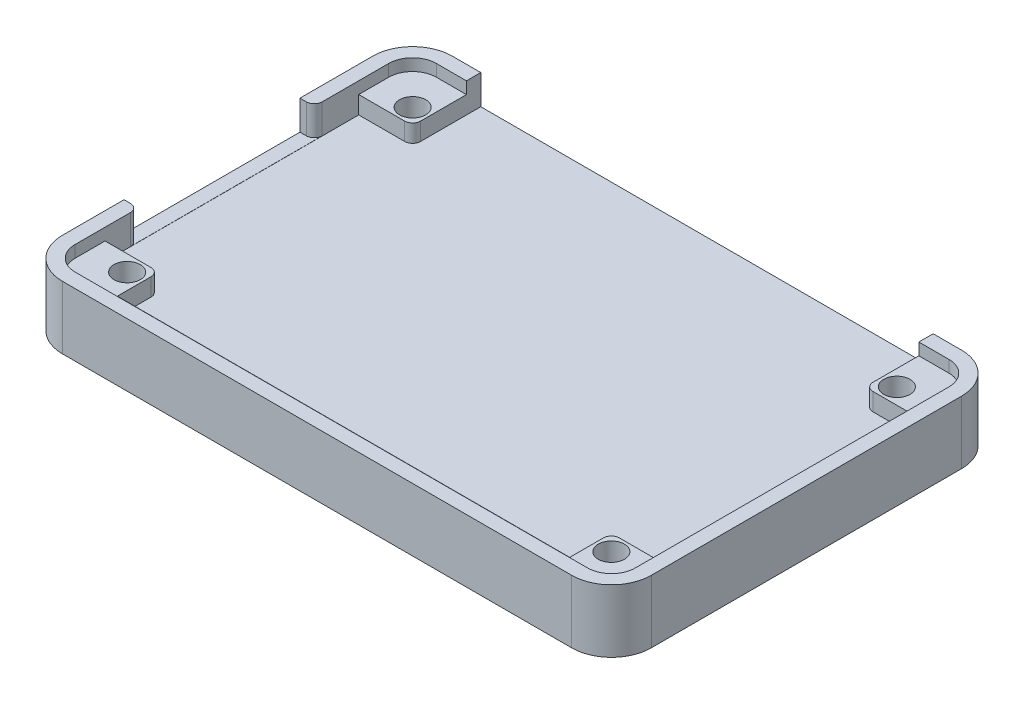
from build123d import *

# Parameters (mm, degrees)
SKETCH1_W           = 74
SKETCH1_H           = 49
BOSS_EXTRUDE1_DEPTH = 7.9
FILLET1_R           = 5
CUT_EXTRUDE4_DEPTH  = 3.72
SKETCH3_R           = 1.65
CUT_EXTRUDE6_DEPTH  = 7.9
SKETCH7_W           = 22.1
SKETCH7_H           = 3.7
CUT_EXTRUDE7_DEPTH  = 3
SKETCH8_W           = 70.4
SKETCH8_H           = 45.4
CUT_EXTRUDE8_DEPTH  = 1.5
FILLET3_R           = 3
FILLET4_R           = 1
FILLET5_R           = 1
FILLET6_R           = 1


with BuildPart() as part:
    # Sketch1 → Boss-Extrude1 (new body)
    with BuildSketch(Plane(origin=(0, 0, 0), x_dir=(1, 0, 0), z_dir=(0, 1, 0))):
        Rectangle(SKETCH1_W, SKETCH1_H)
    extrude(amount=BOSS_EXTRUDE1_DEPTH)

    # Fillet1
    fillet1_edges = [part.edges().sort_by_distance(p)[0] for p in [
        (37, 3.95, 24.5),
        (-37, 3.95, 24.5),
        (-37, 3.95, -24.5),
        (37, 3.95, -24.5),
    ]]
    fillet(fillet1_edges, radius=FILLET1_R)

    # Sketch5 → Cut-Extrude4 (cut)
    with BuildSketch(Plane(origin=(0, 7.9, 0), x_dir=(1, 0, 0), z_dir=(0, 1, 0))):
        Polygon((-35.2, 15.9375), (-28.424, 15.9375), (-28.424, 21.171805633), (-28.424, 24.5), (28.424, 24.5), (28.424, 21.171805633), (28.424, 15.9375), (35.2, 15.9375), (35.2, -15.9375), (28.424, -15.9375), (28.424, -21.17), (-28.424, -21.17), (-28.424, -15.9375), (-35.2, -15.9375), align=None)
    extrude(amount=-CUT_EXTRUDE4_DEPTH, mode=Mode.SUBTRACT)

    # Sketch3 → Cut-Extrude6 (cut)
    with BuildSketch(Plane(origin=(0, 7.9, 0), x_dir=(1, 0, 0), z_dir=(0, 1, 0))):
        with Locations((-30.424, 17.9375)):
            Circle(SKETCH3_R)
        with Locations((30.424, 17.9375)):
            Circle(SKETCH3_R)
        with Locations((-30.424, -17.9375)):
            Circle(SKETCH3_R)
        with Locations((30.424, -17.9375)):
            Circle(SKETCH3_R)
    extrude(amount=-CUT_EXTRUDE6_DEPTH, mode=Mode.SUBTRACT)

    # Sketch7 → Cut-Extrude7 (cut)
    with BuildSketch(Plane.ZY.offset(37)):
        with Locations((0.7, 6.05)):
            Rectangle(SKETCH7_W, SKETCH7_H)
    extrude(amount=-CUT_EXTRUDE7_DEPTH, mode=Mode.SUBTRACT)

    # Sketch8 → Cut-Extrude8 (cut)
    with BuildSketch(Plane(origin=(0, 7.9, 0), x_dir=(1, 0, 0), z_dir=(0, 1, 0))):
        Rectangle(SKETCH8_W, SKETCH8_H)
    extrude(amount=-CUT_EXTRUDE8_DEPTH, mode=Mode.SUBTRACT)

    # Fillet3
    fillet3_edges = [part.edges().sort_by_distance(p)[0] for p in [
        (-35.2, 7.15, -22.7),
        (35.2, 7.15, -22.7),
        (-35.2, 7.15, 22.7),
        (35.2, 7.15, 22.7),
    ]]
    fillet(fillet3_edges, radius=FILLET3_R)

    # Fillet4
    fillet4_edges = [part.edges().sort_by_distance(p)[0] for p in [
        (-28.424, 5.29, -15.9375),
        (28.424, 5.29, -15.9375),
    ]]
    fillet(fillet4_edges, radius=FILLET4_R)

    # Fillet5
    fillet5_edges = [part.edges().sort_by_distance(p)[0] for p in [
        (28.424, 5.29, 15.9375),
        (-28.424, 5.29, 15.9375),
    ]]
    fillet(fillet5_edges, radius=FILLET5_R)

    # Fillet6
    fillet6_edges = [part.edges().sort_by_distance(p)[0] for p in [
        (-35.2, 6.05, -10.35),
        (-35.2, 6.05, 11.75),
    ]]
    fillet(fillet6_edges, radius=FILLET6_R)


solid = part.part
